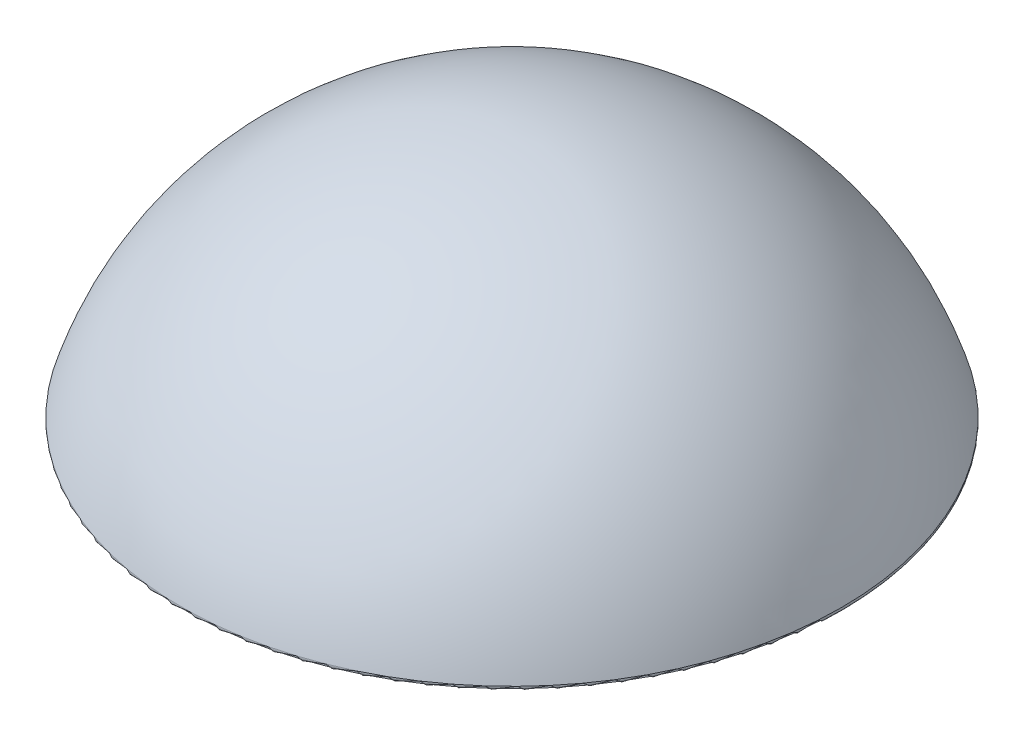
from build123d import *

# Parameters (mm, degrees)
FILLET2_R = 0.5


with BuildPart() as part:
    # Sketch1 → Revolve1 (revolve)
    with BuildSketch(Plane.XY):
        with BuildLine():
            Line((0, 0), (0, 37.46))
            ThreePointArc((0, 37.46), (31.238004098, 27.056220098), (50, 0))
            Line((50, 0), (0, 0))
        make_face()
    revolve(axis=Axis((0, 0, 0), (0, 1, 0)))

    # Fillet2
    fillet2_edges = [part.edges().sort_by_distance(p)[0] for p in [
        (-50, 0, 0),
    ]]
    fillet(fillet2_edges, radius=FILLET2_R)


solid = part.part
